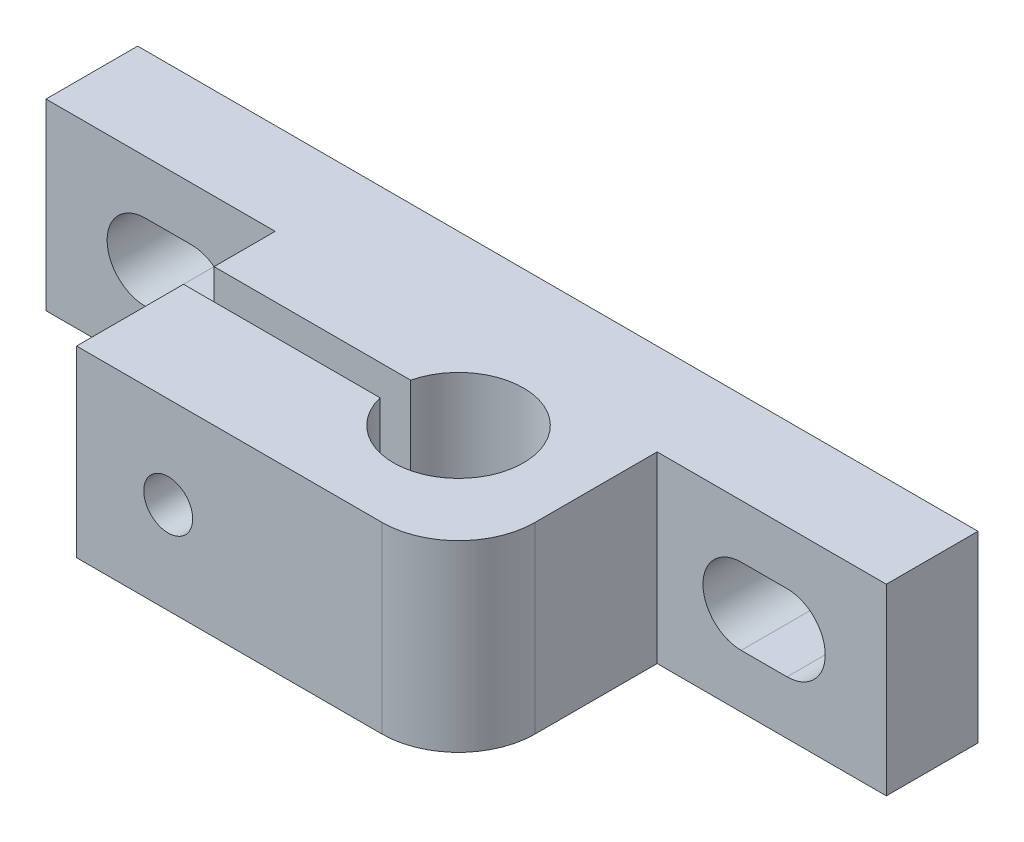
from build123d import *

# Parameters (mm, degrees)
SKETCH2_W           = 55
SKETCH2_H           = 12
BOSS_EXTRUDE1_DEPTH = 6
SKETCH3_W           = 25
SKETCH3_H           = 12
BOSS_EXTRUDE2_DEPTH = 13
FILLET1_R           = 5
SKETCH4_R           = 4.25
CUT_EXTRUDE2_DEPTH  = 30
SKETCH5_W           = 20.513890507
SKETCH5_H           = 7
CUT_EXTRUDE3_DEPTH  = 5
SKETCH6_R           = 1.6
CUT_EXTRUDE4_DEPTH  = 11
CUT_EXTRUDE5_DEPTH  = 3


with BuildPart() as part:
    # Sketch2 → Boss-Extrude1 (new body)
    with BuildSketch(Plane.XY):
        with Locations((27.5, 6)):
            Rectangle(SKETCH2_W, SKETCH2_H)
        with BuildLine():
            Line((6.5, 8.5), (9.5, 8.5))
            ThreePointArc((9.5, 8.5), (12, 6), (9.5, 3.5))
            Line((9.5, 3.5), (6.5, 3.5))
            ThreePointArc((6.5, 3.5), (4, 6), (6.5, 8.5))
        make_face(mode=Mode.SUBTRACT)
        with BuildLine():
            Line((48.5, 8.5), (45.5, 8.5))
            ThreePointArc((45.5, 8.5), (43, 6), (45.5, 3.5))
            Line((45.5, 3.5), (48.5, 3.5))
            ThreePointArc((48.5, 3.5), (51, 6), (48.5, 8.5))
        make_face(mode=Mode.SUBTRACT)
    extrude(amount=BOSS_EXTRUDE1_DEPTH)

    # Sketch3 → Boss-Extrude2 (add)
    with BuildSketch(Plane.XY.offset(6)):
        with Locations((27.5, 6)):
            Rectangle(SKETCH3_W, SKETCH3_H)
    extrude(amount=BOSS_EXTRUDE2_DEPTH)

    # Fillet1
    fillet1_edges = [part.edges().sort_by_distance(p)[0] for p in [
        (40, 6, 19),
    ]]
    fillet(fillet1_edges, radius=FILLET1_R)

    # Sketch4 → Cut-Extrude2 (cut)
    with BuildSketch(Plane.XZ):
        with BuildLine():
            ThreePointArc((27.86932209, 10), (27.75, 11), (27.86932209, 12))
            Line((27.86932209, 12), (15, 12))
            Line((15, 12), (15, 10))
            Line((15, 10), (27.86932209, 10))
        make_face()
        with Locations((32, 11)):
            Circle(SKETCH4_R)
    extrude(amount=-CUT_EXTRUDE2_DEPTH, mode=Mode.SUBTRACT)

    # Sketch5 → Cut-Extrude3 (cut)
    with BuildSketch(Plane(origin=(0, 0, 0), x_dir=(-1, 0, 0), z_dir=(0, 0, -1))):
        with Locations((-27.415473723, 6)):
            Rectangle(SKETCH5_W, SKETCH5_H)
    extrude(amount=-CUT_EXTRUDE3_DEPTH, mode=Mode.SUBTRACT)

    # Sketch6 → Cut-Extrude4 (cut)
    with BuildSketch(Plane.XY.offset(19)):
        with Locations((21, 6)):
            Circle(SKETCH6_R)
    extrude(amount=-CUT_EXTRUDE4_DEPTH, mode=Mode.SUBTRACT)

    # Sketch7 → Cut-Extrude5 (cut)
    with BuildSketch(Plane(origin=(0, 0, 5), x_dir=(-1, 0, 0), z_dir=(0, 0, -1))):
        Polygon((-17.535898385, 6), (-19.267949192, 9), (-22.732050808, 9), (-24.464101615, 6), (-22.732050808, 3), (-19.267949192, 3), align=None)
    extrude(amount=-CUT_EXTRUDE5_DEPTH, mode=Mode.SUBTRACT)


solid = part.part
